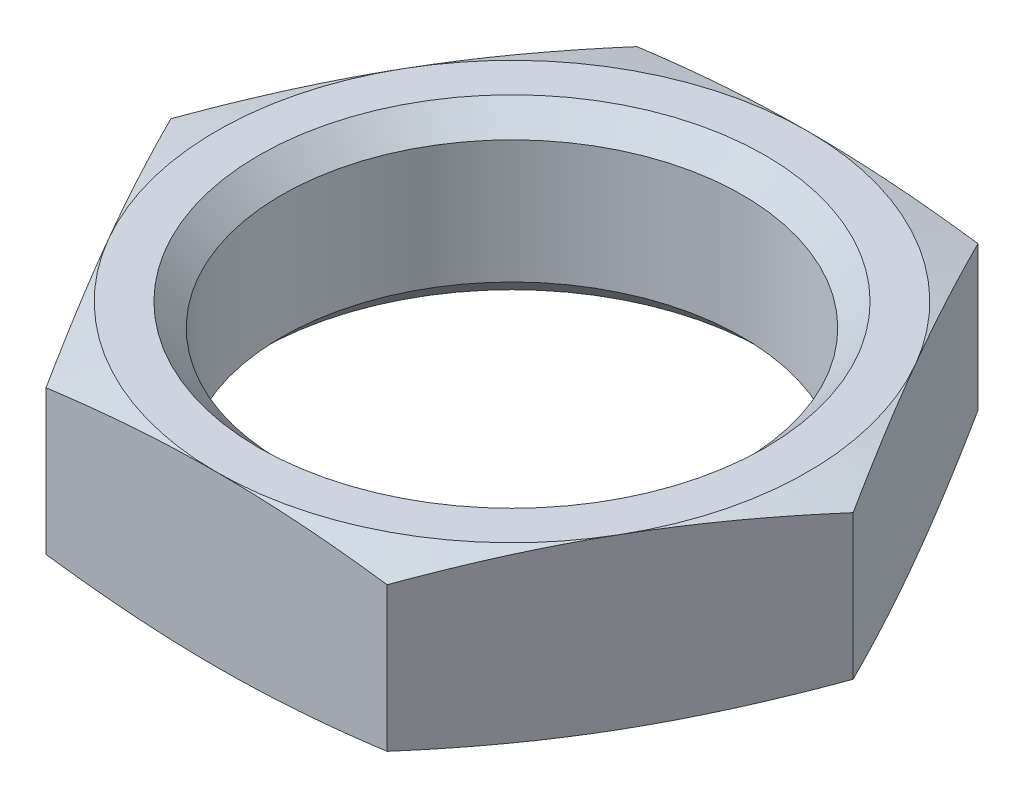
from build123d import *

# Parameters (mm, degrees)
SKETCH3_W          = 68
SKETCH3_H          = 68
CUT_EXTRUDE1_DEPTH = 4


with BuildPart() as part:
    # Sketch1 → Revolve1 (revolve)
    with BuildSketch(Plane.XY):
        Polygon((0, 23), (7, 23), (8.4, 22.624871131), (8.4, 19.375128869), (7, 19), (0, 19), align=None)
    revolve(axis=Axis((0, 19, 0), (0, 1, 0)))

    # Sketch2 → Cut-Revolve1 (revolve, cut)
    with BuildSketch(Plane.XY):
        Polygon((0, 23), (6, 23), (5.4585, 22.4585), (5.4585, 19.5415), (6, 19), (0, 19), align=None)
    revolve(axis=Axis((0, 19, 0), (0, 1, 0)), mode=Mode.SUBTRACT)

    # Sketch3 → Cut-Extrude1 (cut)
    with BuildSketch(Plane(origin=(0, 19, 0), x_dir=(-1, 0, 0), z_dir=(0, 1, 0))):
        Rectangle(SKETCH3_W, SKETCH3_H)
        Polygon((8.082903769, 0), (4.041451884, 7), (-4.041451884, 7), (-8.082903769, 0), (-4.041451884, -7), (4.041451884, -7), align=None, mode=Mode.SUBTRACT)
    extrude(amount=CUT_EXTRUDE1_DEPTH, mode=Mode.SUBTRACT)


solid = part.part
